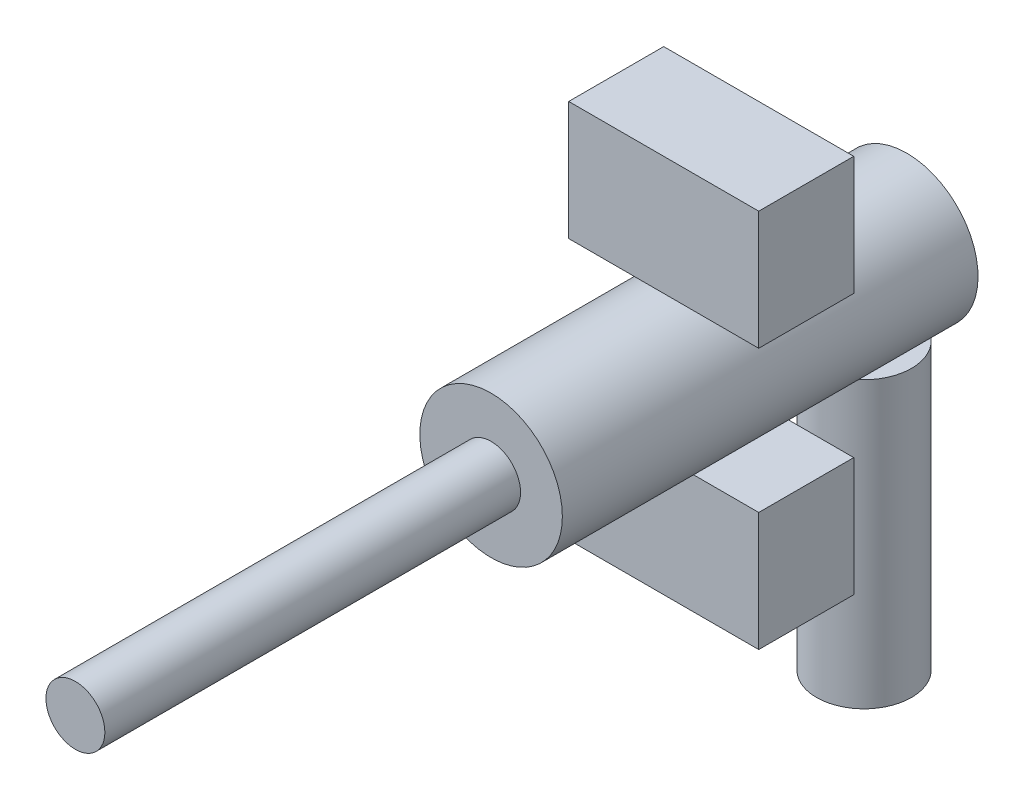
from build123d import *

# Parameters (mm, degrees)
SKETCH1_R                = 20
BOSS_EXTRUDE1_DEPTH      = 120
SKETCH2_R                = 30
BOSS_EXTRUDE2_DEPTH      = 175
SKETCH3_R                = 12.400920413
BOSS_EXTRUDE3_DEPTH      = 175
BOSS_EXTRUDE4_DEPTH      = 40
BOSS_EXTRUDE4_DEPTH_BACK = 40
SKETCH4_W                = 40
SKETCH4_H                = 50


with BuildPart() as part:
    # Sketch1 → Boss-Extrude1 (new body)
    with BuildSketch(Plane(origin=(0, 0, 17.988233235), x_dir=(1, 0, 0), z_dir=(0, 1, 0))):
        Circle(SKETCH1_R)
    extrude(amount=BOSS_EXTRUDE1_DEPTH)

    # Sketch2 → Boss-Extrude2 (add)
    with BuildSketch(Plane.XY):
        with Locations((0, 149.487531085)):
            Circle(SKETCH2_R)
    extrude(amount=BOSS_EXTRUDE2_DEPTH)

    # Sketch3 → Boss-Extrude3 (add)
    with BuildSketch(Plane.XY.offset(175)):
        with Locations((0, 149.487531085)):
            Circle(SKETCH3_R)
    extrude(amount=BOSS_EXTRUDE3_DEPTH)

    # Sketch4 → Boss-Extrude4 (add, two sides: drawn at the far end of the back side and taken through both)
    with BuildSketch(Plane(origin=(0, 0, 0), x_dir=(0, 0, -1), z_dir=(1, 0, 0)).offset(-BOSS_EXTRUDE4_DEPTH_BACK)):
        with Locations((-82.321831747, 94.641687433)):
            Rectangle(SKETCH4_W, SKETCH4_H)
        with Locations((-82.321831747, 204.487531085)):
            Rectangle(SKETCH4_W, SKETCH4_H)
    extrude(amount=BOSS_EXTRUDE4_DEPTH + BOSS_EXTRUDE4_DEPTH_BACK)


with BuildPart() as boss_extrude4_piece_1:
    # of the separate pieces the step leaves, piece 1, a body of its own (boss_extrude4_pieces)
    add(part.part.solids().sort_by_distance((20, 0, 17.988233235))[0])


with BuildPart() as boss_extrude4_piece_2:
    # of the separate pieces the step leaves, piece 2, a body of its own (boss_extrude4_pieces)
    add(part.part.solids().sort_by_distance((40, 179.487531085, 102.321831747))[0])


solid = Compound([boss_extrude4_piece_1.part, boss_extrude4_piece_2.part])
